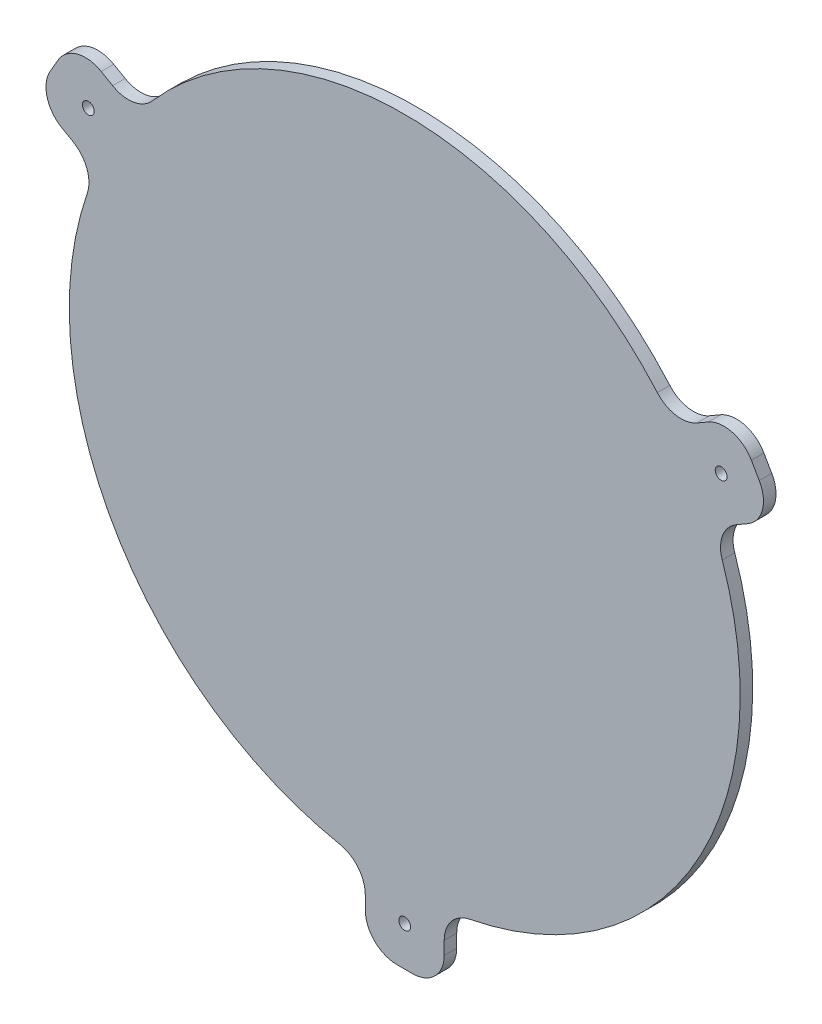
from build123d import *

# Parameters (mm, degrees)
SKETCH1_R                = 85
BOSS_EXTRUDE1_DEPTH      = 3.175
SKETCH2_W                = 20
SKETCH2_H                = 18.160284919
SKETCH2_R                = 1.5
BOSS_EXTRUDE2_DEPTH      = 3.175
FILLET1_R                = 8
CIRPATTERN1_COUNT        = 3
FILLET1_OF_CIRPATTERN1_R = 8


with BuildPart() as part:
    # Sketch1 → Boss-Extrude1 (new body)
    with BuildSketch(Plane.XY):
        Circle(SKETCH1_R)
    extrude(amount=BOSS_EXTRUDE1_DEPTH)

    # Sketch2 → Boss-Extrude2 (add, through all)
    with BuildSketch(Plane.XY):
        with Locations((0, -93.48985754)):
            Rectangle(SKETCH2_W, SKETCH2_H)
        with Locations((0, -92.57)):
            Circle(SKETCH2_R, mode=Mode.SUBTRACT)
    boss_extrude2 = extrude(amount=BOSS_EXTRUDE2_DEPTH)

    # Fillet1
    fillet1_edges = [part.edges().sort_by_distance(p)[0] for p in [
        (-10, -84.409715081, 1.5875),
        (-10, -102.57, 1.5875),
        (10, -102.57, 1.5875),
        (10, -84.409715081, 1.5875),
    ]]
    fillet(fillet1_edges, radius=FILLET1_R)

    # CirPattern1: Boss-Extrude2 ×3 about axis
    cirpattern1_axis = Axis((0, 0, 0), (0, 0, 1))
    for i in range(1, CIRPATTERN1_COUNT):
        add(boss_extrude2.rotate(cirpattern1_axis, i * 360 / CIRPATTERN1_COUNT))

    # Fillet1 of CirPattern1
    fillet1_of_cirpattern1_edges = [part.edges().sort_by_distance(p)[0] for p in [
        (78.100957586, 33.544603502, 1.5875),
        (93.828225666, 42.624745962, 1.5875),
        (83.828225666, 59.945254038, 1.5875),
        (68.100957586, 50.865111578, 1.5875),
        (-68.100957586, 50.865111578, 1.5875),
        (-83.828225666, 59.945254038, 1.5875),
        (-93.828225666, 42.624745962, 1.5875),
        (-78.100957586, 33.544603502, 1.5875),
    ]]
    fillet(fillet1_of_cirpattern1_edges, radius=FILLET1_OF_CIRPATTERN1_R)


solid = part.part
